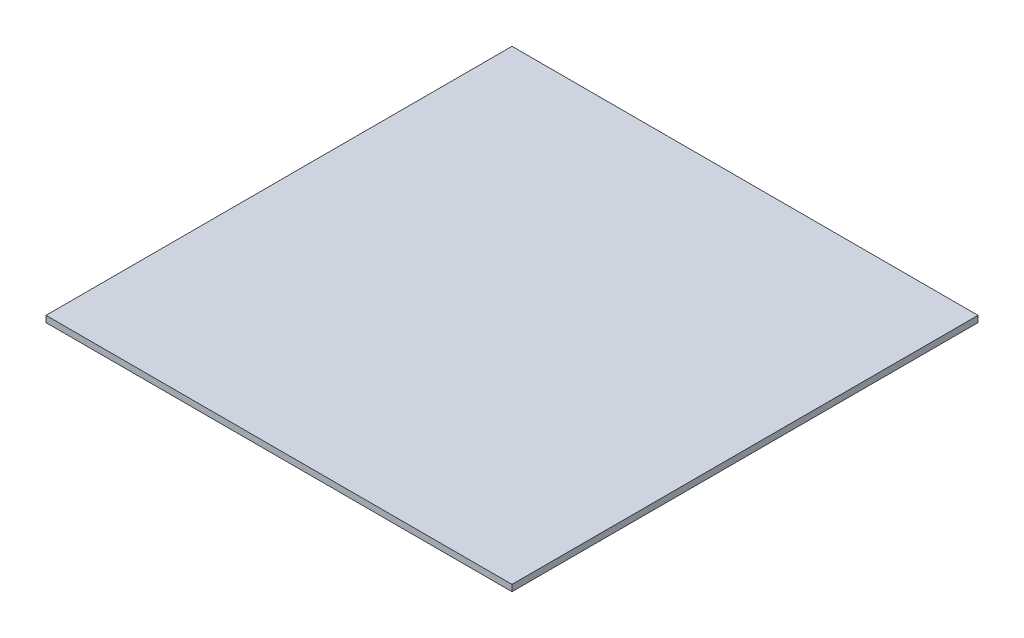
from build123d import *

# Parameters (mm, degrees)
SKETCH1_W           = 220
SKETCH1_H           = 220
BOSS_EXTRUDE1_DEPTH = 3


with BuildPart() as part:
    # Sketch1 → Boss-Extrude1 (new body)
    with BuildSketch(Plane(origin=(0, 0, 0), x_dir=(1, 0, 0), z_dir=(0, 1, 0))):
        with Locations((-11.244370767, 28.741551992)):
            Rectangle(SKETCH1_W, SKETCH1_H)
    extrude(amount=BOSS_EXTRUDE1_DEPTH)


solid = part.part
